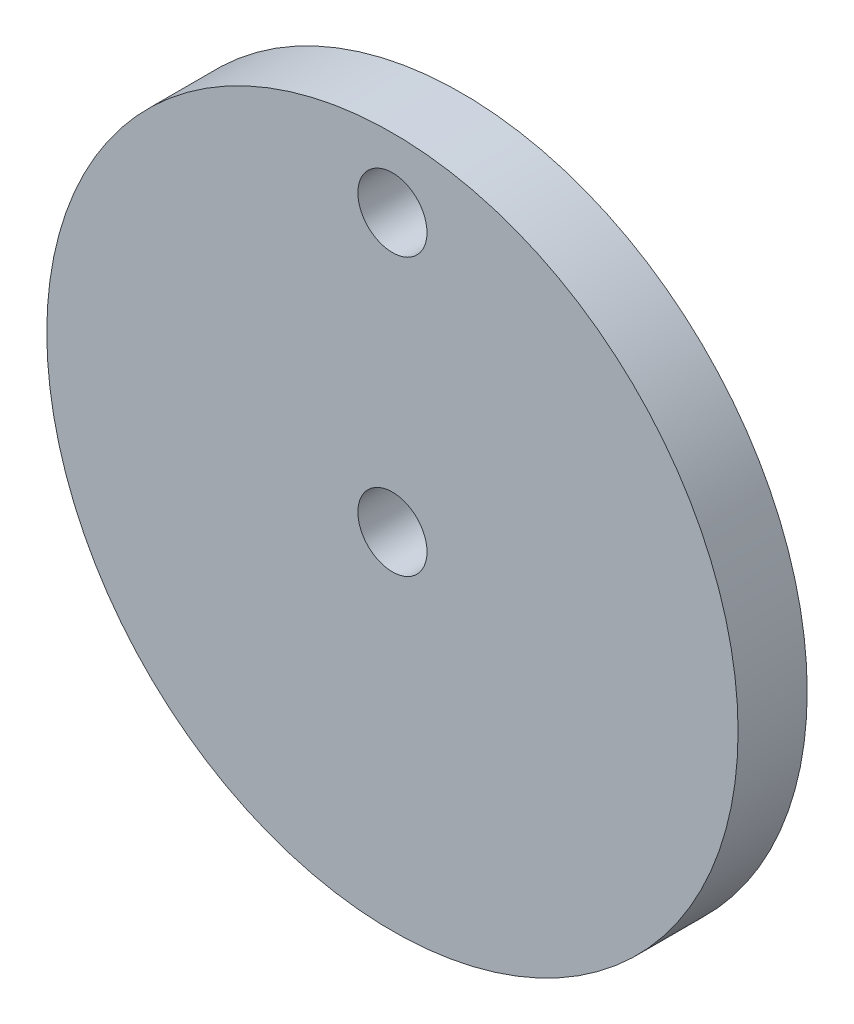
from build123d import *

# Parameters (mm, degrees)
SKETCH1_R           = 50
SKETCH1_R_2         = 5
BOSS_EXTRUDE1_DEPTH = 10


with BuildPart() as part:
    # Sketch1 → Boss-Extrude1 (new body)
    with BuildSketch(Plane.XY):
        Circle(SKETCH1_R)
        Circle(SKETCH1_R_2, mode=Mode.SUBTRACT)
        with Locations((0, 40)):
            Circle(SKETCH1_R_2, mode=Mode.SUBTRACT)
    extrude(amount=BOSS_EXTRUDE1_DEPTH)


solid = part.part
